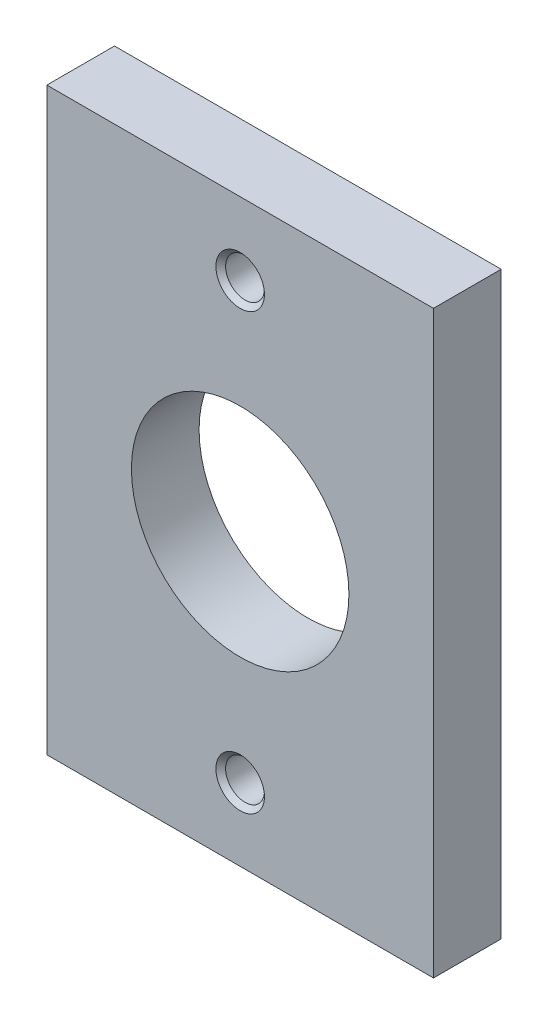
from build123d import *

# Parameters (mm, degrees)
SKETCH1_W                        = 50.8
SKETCH1_H                        = 76.2
SKETCH1_R                        = 14.2875
BOSS_EXTRUDE1_DEPTH              = 8.89
F_10_CLEARANCE_HOLE1_D           = 5.1054
F_10_CLEARANCE_HOLE1_CSINK_D     = 6.3754
F_10_CLEARANCE_HOLE1_CSINK_ANGLE = 90


with BuildPart() as part:
    # Sketch1 → Boss-Extrude1 (new body)
    with BuildSketch(Plane.XY):
        with Locations((25.4, 38.1)):
            Rectangle(SKETCH1_W, SKETCH1_H)
        with Locations((25.4, 38.1)):
            Circle(SKETCH1_R, mode=Mode.SUBTRACT)
    extrude(amount=BOSS_EXTRUDE1_DEPTH)

    # #10 Clearance Hole1 (through all)
    with Locations(Plane.XY.offset(8.89)):
        with Locations((25.4, 66.675), (25.4, 9.525)):
            CounterSinkHole(F_10_CLEARANCE_HOLE1_D / 2, F_10_CLEARANCE_HOLE1_CSINK_D / 2, counter_sink_angle=F_10_CLEARANCE_HOLE1_CSINK_ANGLE)


solid = part.part
